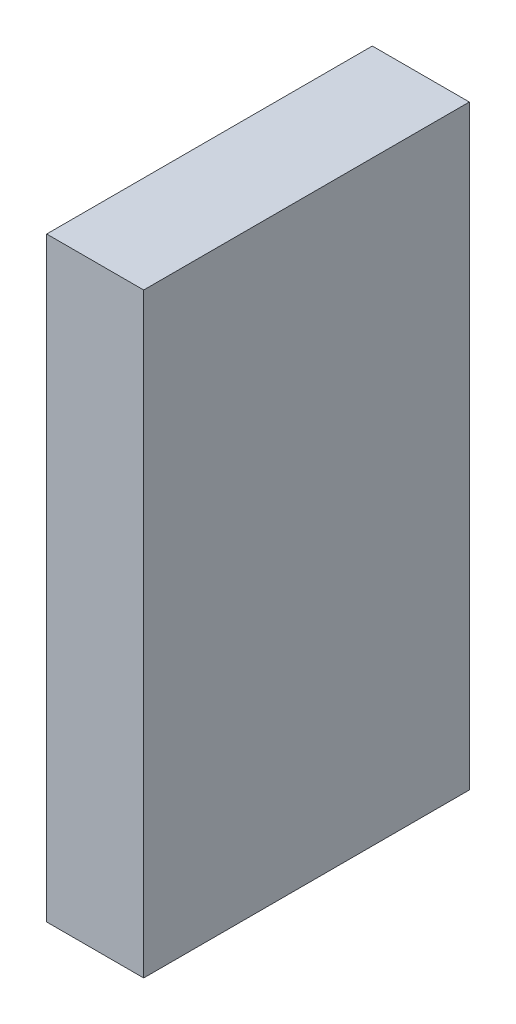
from build123d import *

# Parameters (mm, degrees)
SKETCH1_W           = 0.7
SKETCH1_H           = 4.3
BOSS_EXTRUDE1_DEPTH = 2.35


with BuildPart() as part:
    # Sketch1 → Boss-Extrude1 (new body)
    with BuildSketch(Plane.XY):
        Rectangle(SKETCH1_W, SKETCH1_H)
    extrude(amount=BOSS_EXTRUDE1_DEPTH)


solid = part.part
